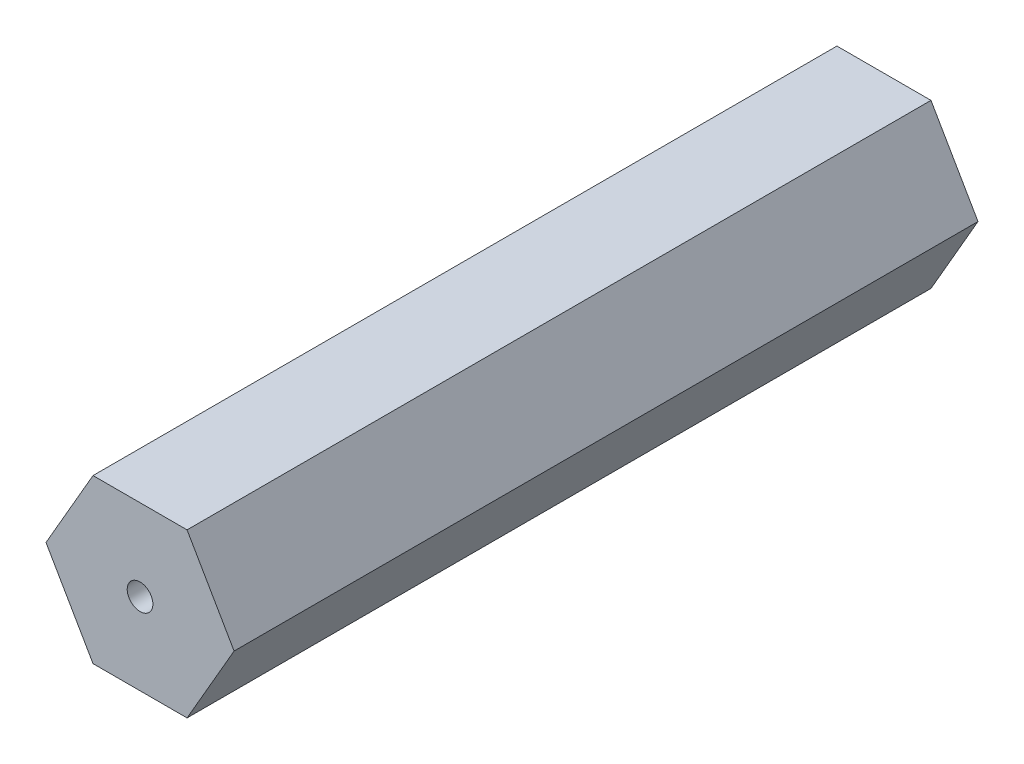
from build123d import *

# Parameters (mm, degrees)
BOSS_EXTRUDE1_DEPTH = 58
SKETCH2_R           = 1
CUT_EXTRUDE1_DEPTH  = 59


with BuildPart() as part:
    # Sketch1 → Boss-Extrude1 (new body)
    with BuildSketch(Plane.XY):
        Polygon((7.332348419, 0), (3.666174209, 6.35), (-3.666174209, 6.35), (-7.332348419, 0), (-3.666174209, -6.35), (3.666174209, -6.35), align=None)
    extrude(amount=BOSS_EXTRUDE1_DEPTH)

    # Sketch2 → Cut-Extrude1 (cut, through all)
    with BuildSketch(Plane.XY.offset(58)):
        Circle(SKETCH2_R)
    extrude(amount=-CUT_EXTRUDE1_DEPTH, mode=Mode.SUBTRACT)


solid = part.part
